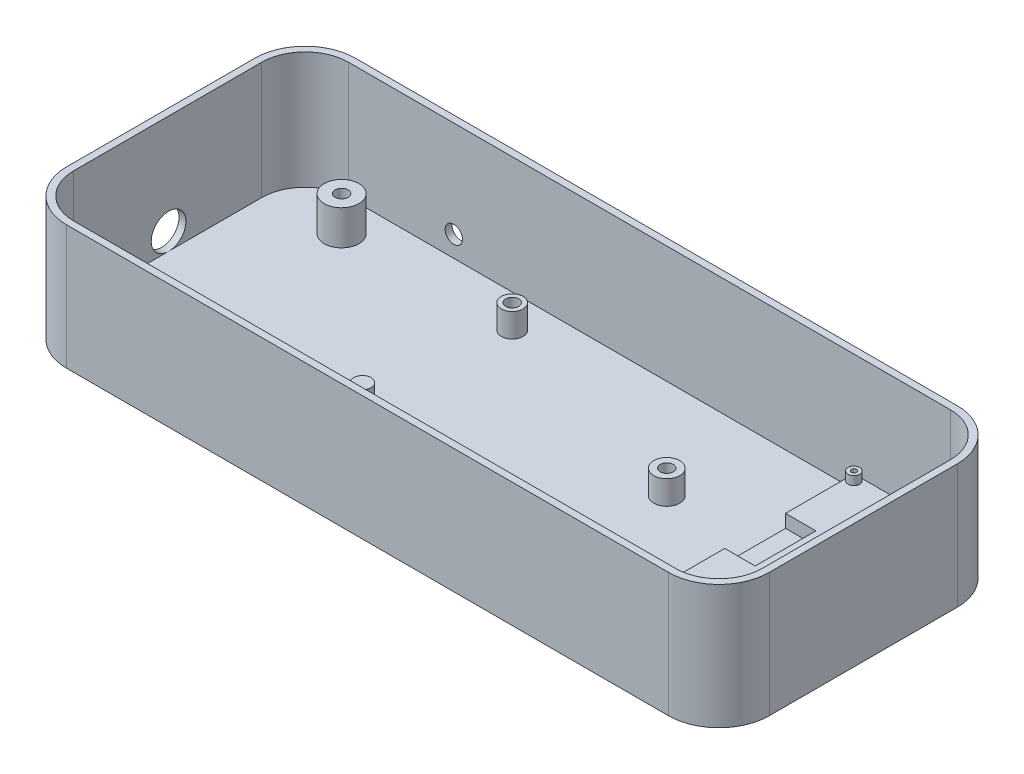
from build123d import *

# Parameters (mm, degrees)
SKETCH5_W                        = 20
SKETCH5_H                        = 45.5
SKETCH5_R                        = 0.55
ULTRASONIC_TRANSDUCER_BASE_DEPTH = 11
ULTRASONIC_PINS_CUTAWAY_DEPTH    = 3
STANDOFF_PROFILE_R               = 1.35
ULTRASONIC_STANDOFFS_DEPTH       = 2
ENCLOSURE_OUTER_LIMIT_W          = 158.6
ENCLOSURE_OUTER_LIMIT_H          = 63.3
ENCLOSURE_BASE_DEPTH             = 1.6
ENCLOSURE_FILLET_R               = 10
SKETCH9_R                        = 2.5
SKETCH9_R_2                      = 3
SKETCH9_R_3                      = 2
UNO_STANDOFFS_DEPTH              = 5.5
UNO_START                        = 1
SKETCH11_R                       = 1.5
UNO_STANDOFF_SCREW_HOLES_DEPTH   = 4.5
ENCLOSURE_WALL_DEPTH             = 27
ENCLOSURE_WALL_DEPTH_BACK        = 1.6
SKETCH13_R                       = 4
LED_RING_CABLE_HOLE_DEPTH        = 1.6
SKETCH14_R                       = 4
BUS_SCREW_POSTS_DEPTH            = 8
SKETCH15_R                       = 1.5
BUS_SCREW_HOLES_DEPTH            = 6
SKETCH16_R                       = 2
POWER_CORD_HOLE_DEPTH            = 1.6
FILLET1_R                        = 1.5
SKETCH6_R                        = 0.6
CUT_PIN_HOLES_DEPTH              = 10


with BuildPart() as part:
    # Sketch5 → Ultrasonic Transducer Base (new body)
    with BuildSketch(Plane(origin=(0, 0, 0), x_dir=(1, 0, 0), z_dir=(0, 1, 0))):
        with Locations((70, 1)):
            Rectangle(SKETCH5_W, SKETCH5_H)
        with Locations((61.4, 22.35)):
            Circle(SKETCH5_R, mode=Mode.SUBTRACT)
        with Locations((78.6, 22.35)):
            Circle(SKETCH5_R, mode=Mode.SUBTRACT)
        with Locations((78.6, -20.35)):
            Circle(SKETCH5_R, mode=Mode.SUBTRACT)
        with Locations((61.4, -20.35)):
            Circle(SKETCH5_R, mode=Mode.SUBTRACT)
    extrude(amount=ULTRASONIC_TRANSDUCER_BASE_DEPTH)

    # Sketch8 → Ultrasonic Pins Cutaway (cut)
    with BuildSketch(Plane(origin=(0, 11, 0), x_dir=(1, 0, 0), z_dir=(0, 1, 0))):
        Polygon((60, 1), (60, -6), (67, -6), (67, 8), (60, 8), align=None)
    extrude(amount=-ULTRASONIC_PINS_CUTAWAY_DEPTH, mode=Mode.SUBTRACT)

    # Standoff Profile → Ultrasonic Standoffs (add)
    with BuildSketch(Plane.XZ.offset(-11)):
        with Locations((61.4, 20.35)):
            Circle(STANDOFF_PROFILE_R)
        with Locations((78.6, 20.35)):
            Circle(STANDOFF_PROFILE_R)
        with Locations((61.4, -22.35)):
            Circle(STANDOFF_PROFILE_R)
        with Locations((78.6, -22.35)):
            Circle(STANDOFF_PROFILE_R)
    extrude(amount=-ULTRASONIC_STANDOFFS_DEPTH)

    # Enclosure Outer Limit → Enclosure Base (add)
    with BuildSketch(Plane(origin=(0, 0, 0), x_dir=(1, 0, 0), z_dir=(0, 1, 0))):
        with Locations((5, 0)):
            Rectangle(ENCLOSURE_OUTER_LIMIT_W, ENCLOSURE_OUTER_LIMIT_H)
    extrude(amount=-ENCLOSURE_BASE_DEPTH)

    # Enclosure Fillet
    enclosure_fillet_edges = [part.edges().sort_by_distance(p)[0] for p in [
        (-74.3, -0.8, -31.65),
        (84.3, -0.8, -31.65),
        (84.3, -0.8, 31.65),
        (-74.3, -0.8, 31.65),
    ]]
    fillet(enclosure_fillet_edges, radius=ENCLOSURE_FILLET_R)

    # Sketch9 → Uno Standoffs (add)
    with BuildSketch(Plane(origin=(0, 0, 0), x_dir=(1, 0, 0), z_dir=(0, 1, 0))):
        with Locations((-19, 24.05)):
            Circle(SKETCH9_R)
        with Locations((31.8, 8.85)):
            Circle(SKETCH9_R_2)
        with Locations((31.8, -19.05)):
            Circle(SKETCH9_R_2)
        with Locations((-20.3, -24.15)):
            Circle(SKETCH9_R)
        with Locations((-20.3, -9.15)):
            Circle(SKETCH9_R_3)
    extrude(amount=UNO_STANDOFFS_DEPTH)

    # Sketch11 → Uno Standoff Screw Holes (cut)
    with BuildSketch(Plane(origin=(0, 0, 0), x_dir=(1, 0, 0), z_dir=(0, 1, 0)).offset(UNO_START)):
        with Locations((-19, 24.05)):
            Circle(SKETCH11_R)
        with Locations((31.8, 8.85)):
            Circle(SKETCH11_R)
        with Locations((31.8, -19.05)):
            Circle(SKETCH11_R)
        with Locations((-20.3, -24.15)):
            Circle(SKETCH11_R)
    extrude(amount=UNO_STANDOFF_SCREW_HOLES_DEPTH, mode=Mode.SUBTRACT)

    # Sketch12 → Enclosure Wall (add, two sides)
    with BuildSketch(Plane(origin=(0, 0, 0), x_dir=(1, 0, 0), z_dir=(0, 1, 0))) as enclosure_wall_sk:
        with BuildLine():
            Line((85.9, -21.65), (85.9, 21.65))
            ThreePointArc((85.9, 21.65), (82.502438662, 29.852438662), (74.3, 33.25))
            Line((74.3, 33.25), (-64.3, 33.25))
            ThreePointArc((-64.3, 33.25), (-72.502438662, 29.852438662), (-75.9, 21.65))
            Line((-75.9, 21.65), (-75.9, -21.65))
            ThreePointArc((-75.9, -21.65), (-72.502438662, -29.852438662), (-64.3, -33.25))
            Line((-64.3, -33.25), (74.3, -33.25))
            ThreePointArc((74.3, -33.25), (82.502438662, -29.852438662), (85.9, -21.65))
        make_face()
        with BuildLine():
            Line((84.3, -21.65), (84.3, 21.65))
            ThreePointArc((84.3, 21.65), (81.371067812, 28.721067812), (74.3, 31.65))
            Line((74.3, 31.65), (-64.3, 31.65))
            ThreePointArc((-64.3, 31.65), (-71.371067812, 28.721067812), (-74.3, 21.65))
            Line((-74.3, 21.65), (-74.3, -21.65))
            ThreePointArc((-74.3, -21.65), (-71.371067812, -28.721067812), (-64.3, -31.65))
            Line((-64.3, -31.65), (74.3, -31.65))
            ThreePointArc((74.3, -31.65), (81.371067812, -28.721067812), (84.3, -21.65))
        make_face(mode=Mode.SUBTRACT)
    extrude(amount=ENCLOSURE_WALL_DEPTH)
    extrude(enclosure_wall_sk.sketch, amount=-ENCLOSURE_WALL_DEPTH_BACK)

    # Sketch13 → LED Ring Cable Hole (cut)
    with BuildSketch(Plane.ZY.offset(75.9)):
        with Locations((-0.209219048, 4)):
            Circle(SKETCH13_R)
    extrude(amount=-LED_RING_CABLE_HOLE_DEPTH, mode=Mode.SUBTRACT)

    # Sketch14 → Bus Screw Posts (add)
    with BuildSketch(Plane(origin=(0, 0, 0), x_dir=(1, 0, 0), z_dir=(0, 1, 0))):
        with Locations((-57.9, 23.65)):
            Circle(SKETCH14_R)
        with Locations((-57.9, -23.65)):
            Circle(SKETCH14_R)
    extrude(amount=BUS_SCREW_POSTS_DEPTH)

    # Sketch15 → Bus Screw Holes (cut)
    with BuildSketch(Plane(origin=(0, 8, 0), x_dir=(1, 0, 0), z_dir=(0, 1, 0))):
        with Locations((-57.9, 23.65)):
            Circle(SKETCH15_R)
        with Locations((-57.9, -23.65)):
            Circle(SKETCH15_R)
    extrude(amount=-BUS_SCREW_HOLES_DEPTH, mode=Mode.SUBTRACT)

    # Sketch16 → Power Cord Hole (cut)
    with BuildSketch(Plane(origin=(0, 0, -33.25), x_dir=(-1, 0, 0), z_dir=(0, 0, -1))):
        with Locations((40.05731821, 4.801042168)):
            Circle(SKETCH16_R)
    extrude(amount=-POWER_CORD_HOLE_DEPTH, mode=Mode.SUBTRACT)

    # Fillet1
    fillet1_edges = [part.edges().sort_by_distance(p)[0] for p in [
        (80, 5.5, 21.75),
        (60, 5.5, 21.75),
        (60, 5.5, -23.75),
        (80, 5.5, -23.75),
    ]]
    fillet(fillet1_edges, radius=FILLET1_R)

    # Sketch6 → Cut Pin Holes (cut)
    with BuildSketch(Plane(origin=(0, 11, 0), x_dir=(1, 0, 0), z_dir=(0, 1, 0))):
        with Locations((61.4, 22.35)):
            Circle(SKETCH6_R)
        with Locations((78.6, 22.35)):
            Circle(SKETCH6_R)
        with Locations((78.6, -20.35)):
            Circle(SKETCH6_R)
        with Locations((61.4, -20.35)):
            Circle(SKETCH6_R)
    extrude(amount=CUT_PIN_HOLES_DEPTH, mode=Mode.SUBTRACT)


solid = part.part
